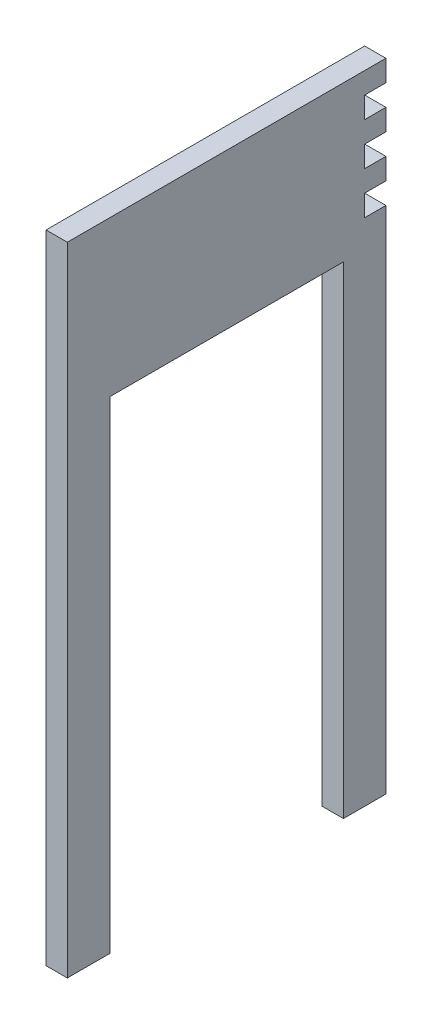
from build123d import *

# Parameters (mm, degrees)
BOSS_EXTRU_1_DEPTH         = 10
ESQUISSE2_W                = 10
ESQUISSE2_H                = 10
ENL_V_MAT_EXTRU_1_DEPTH    = 10
R_P_TITION_LIN_AIRE1_COUNT = 3
R_P_TITION_LIN_AIRE1_PITCH = 20


with BuildPart() as part:
    # Esquisse1 → Boss.-Extru.1 (new body)
    with BuildSketch(Plane(origin=(0, 0, 0), x_dir=(0, 0, -1), z_dir=(1, 0, 0))):
        Polygon((0, -300), (-20, -300), (-20, -73), (-130, -73), (-130, -300), (-150, -300), (-150, 0), (0, 0), align=None)
    extrude(amount=BOSS_EXTRU_1_DEPTH)

    # Esquisse2 → Enlèv. mat.-Extru.1 (cut)
    with BuildSketch(Plane(origin=(10, 0, 0), x_dir=(0, 0, -1), z_dir=(1, 0, 0))):
        with Locations((-5, -15)):
            Rectangle(ESQUISSE2_W, ESQUISSE2_H)
    enl_v_mat_extru_1 = extrude(amount=-ENL_V_MAT_EXTRU_1_DEPTH, mode=Mode.SUBTRACT)

    # Répétition linéaire1: Enlèv. mat.-Extru.1 ×3
    with Locations(*[(0, -i * R_P_TITION_LIN_AIRE1_PITCH, 0) for i in range(1, R_P_TITION_LIN_AIRE1_COUNT)]):
        add(enl_v_mat_extru_1, mode=Mode.SUBTRACT)


solid = part.part
